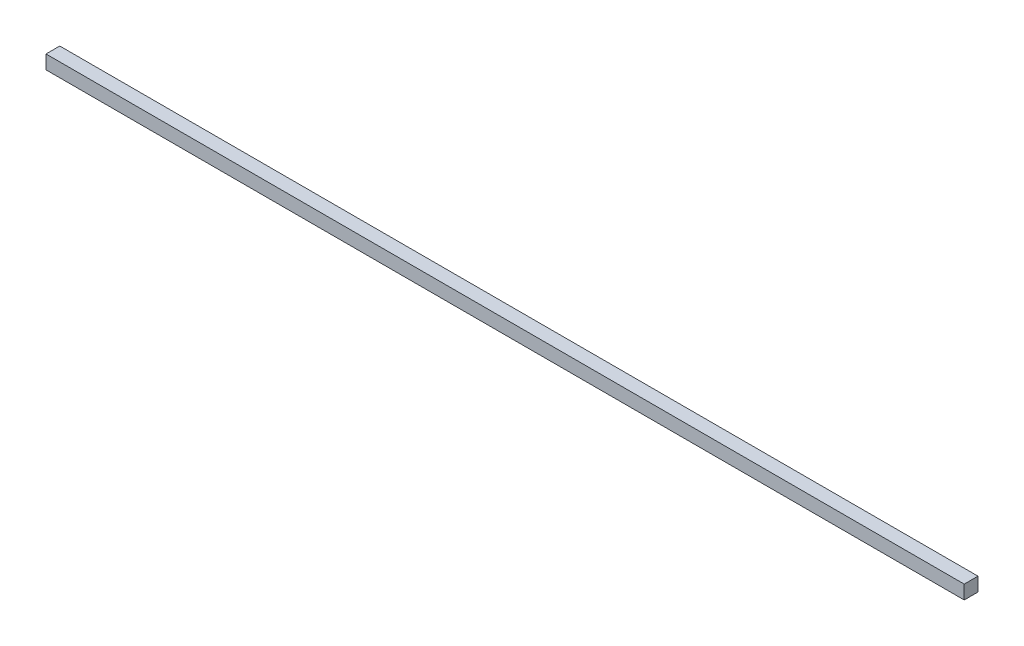
from build123d import *

# Parameters (mm, degrees)
SKETCH_1_W      = 2000
SKETCH_1_H      = 30
EXTRUDE_1_DEPTH = 30


with BuildPart() as part:
    # Эскиз1 → Бобышка-Вытянуть1 (new body)
    with BuildSketch(Plane(origin=(0, 0, 0), x_dir=(1, 0, 0), z_dir=(0, 1, 0))):
        with Locations((1000, 15)):
            Rectangle(SKETCH_1_W, SKETCH_1_H)
    extrude(amount=EXTRUDE_1_DEPTH)


solid = part.part
